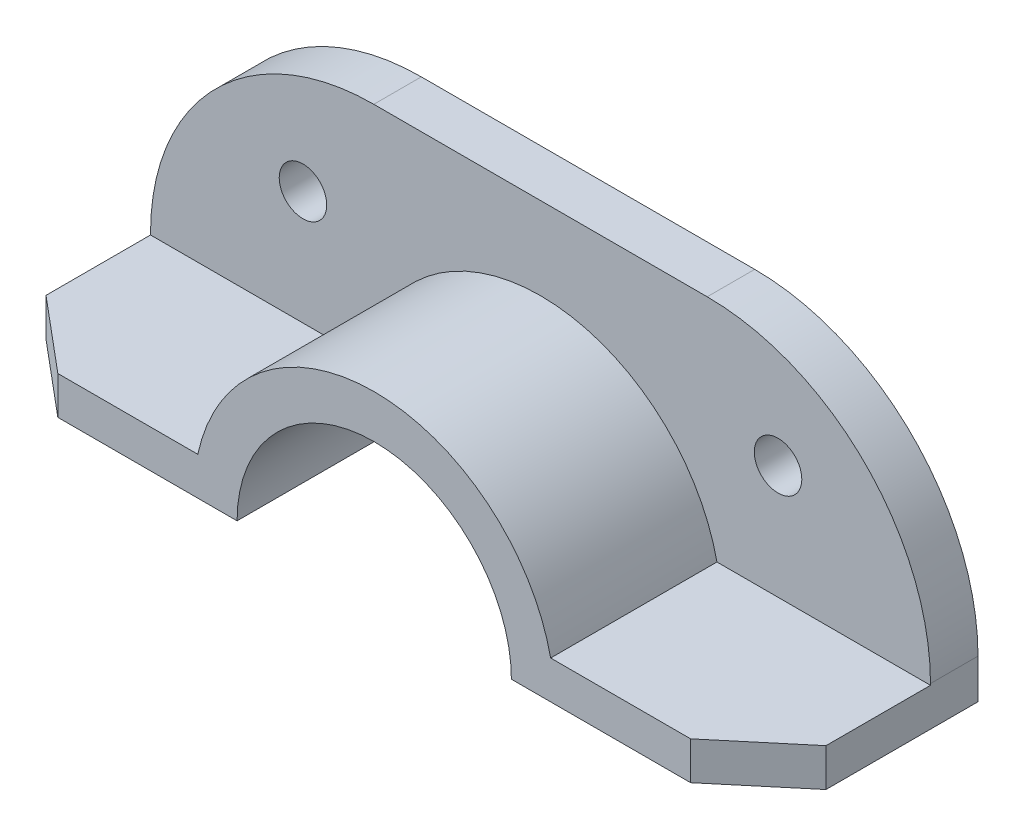
from build123d import *

# Parameters (mm, degrees)
ESTRUSIONE_ESTRUSIONE1_DEPTH = 20
ESTRUSIONE_ESTRUSIONE3_DEPTH = 5
RACCORDO1_R                  = 47
SCHIZZO5_R                   = 5
TAGLIO_ESTRUSIONE1_DEPTH     = 10
TAGLIO_ESTRUSIONE2_DEPTH     = 10
RACCORDO1_OF_SPECCHIA2_R     = 47


with BuildPart() as part:
    # Schizzo1 → Estrusione-Estrusione1 (new body, symmetric)
    with BuildSketch(Plane.XY):
        with BuildLine():
            Line((28.869072897, 0), (82.088181758, 0))
            Line((82.088181758, 0), (82.088181758, 8))
            Line((82.088181758, 8), (37.134650395, 8))
            ThreePointArc((37.134650395, 8), (23.865135757, 29.553976979), (0, 37.986606324))
            Line((0, 37.986606324), (0, 28.869072897))
            ThreePointArc((0, 28.869072897), (20.413517212, 20.413517212), (28.869072897, 0))
        make_face()
    estrusione_estrusione1 = extrude(amount=ESTRUSIONE_ESTRUSIONE1_DEPTH, both=True)

    # Schizzo4 → Estrusione-Estrusione3 (add, symmetric)
    with BuildSketch(Plane(origin=(0, 0, -20), x_dir=(-1, 0, 0), z_dir=(0, 0, -1))):
        with BuildLine():
            Line((-28.869072897, 0), (-82.088181758, 0))
            Line((-82.088181758, 0), (-82.088181758, 55.326384445))
            Line((-82.088181758, 55.326384445), (0, 55.326384445))
            Line((0, 55.326384445), (0, 28.869072897))
            ThreePointArc((0, 28.869072897), (-20.413517212, 20.413517212), (-28.869072897, 0))
        make_face()
    estrusione_estrusione3 = extrude(amount=ESTRUSIONE_ESTRUSIONE3_DEPTH, both=True)

    # Raccordo1
    raccordo1_edges = [part.edges().sort_by_distance(p)[0] for p in [
        (82.088181758, 55.326384445, -20),
    ]]
    fillet(raccordo1_edges, radius=RACCORDO1_R)

    # Schizzo5 → Taglio-Estrusione1 (cut)
    with BuildSketch(Plane.XY.offset(-15)):
        with Locations((50, 32)):
            Circle(SCHIZZO5_R)
    taglio_estrusione1 = extrude(amount=-TAGLIO_ESTRUSIONE1_DEPTH, mode=Mode.SUBTRACT)

    # Schizzo6 → Taglio-Estrusione2 (cut)
    with BuildSketch(Plane(origin=(0, 8, 0), x_dir=(1, 0, 0), z_dir=(0, 1, 0))):
        Polygon((66.595385054, -20), (82.088181758, -7), (82.088181758, -20), align=None)
    taglio_estrusione2 = extrude(amount=-TAGLIO_ESTRUSIONE2_DEPTH, mode=Mode.SUBTRACT)

    # Specchia2: Estrusione-Estrusione1, Estrusione-Estrusione3, Taglio-Estrusione1, Taglio-Estrusione2 across plane
    add(estrusione_estrusione1.mirror(Plane(origin=(0, 0, 0), x_dir=(0, 0, 1), z_dir=(1, 0, 0))))
    add(estrusione_estrusione3.mirror(Plane(origin=(0, 0, 0), x_dir=(0, 0, 1), z_dir=(1, 0, 0))))
    add(taglio_estrusione1.mirror(Plane(origin=(0, 0, 0), x_dir=(0, 0, 1), z_dir=(1, 0, 0))), mode=Mode.SUBTRACT)
    add(taglio_estrusione2.mirror(Plane(origin=(0, 0, 0), x_dir=(0, 0, 1), z_dir=(1, 0, 0))), mode=Mode.SUBTRACT)

    # Raccordo1 of Specchia2
    raccordo1_of_specchia2_edges = [part.edges().sort_by_distance(p)[0] for p in [
        (-82.088181758, 55.326384445, -20),
    ]]
    fillet(raccordo1_of_specchia2_edges, radius=RACCORDO1_OF_SPECCHIA2_R)


solid = part.part
